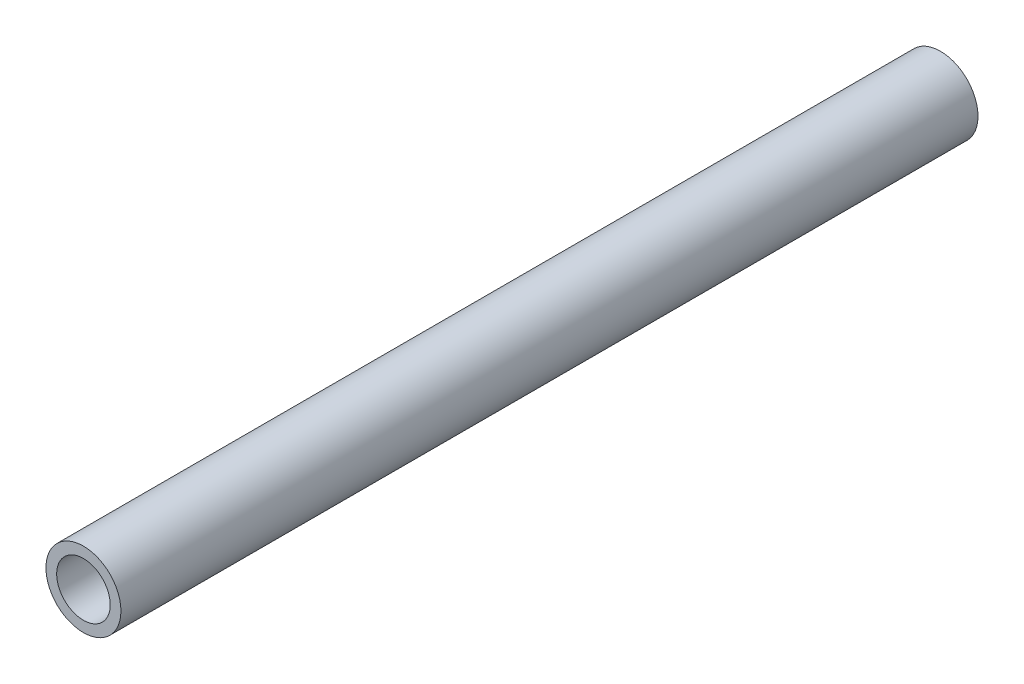
from build123d import *

# Parameters (mm, degrees)
SKETCH1_R           = 13.335
BOSS_EXTRUDE1_DEPTH = 304.8
SKETCH2_R           = 9.525
CUT_EXTRUDE1_DEPTH  = 305.8


with BuildPart() as part:
    # Sketch1 → Boss-Extrude1 (new body)
    with BuildSketch(Plane.XY):
        Circle(SKETCH1_R)
    extrude(amount=BOSS_EXTRUDE1_DEPTH)

    # Sketch2 → Cut-Extrude1 (cut, through all)
    with BuildSketch(Plane(origin=(0, 0, 0), x_dir=(-1, 0, 0), z_dir=(0, 0, -1))):
        Circle(SKETCH2_R)
    extrude(amount=-CUT_EXTRUDE1_DEPTH, mode=Mode.SUBTRACT)


solid = part.part
